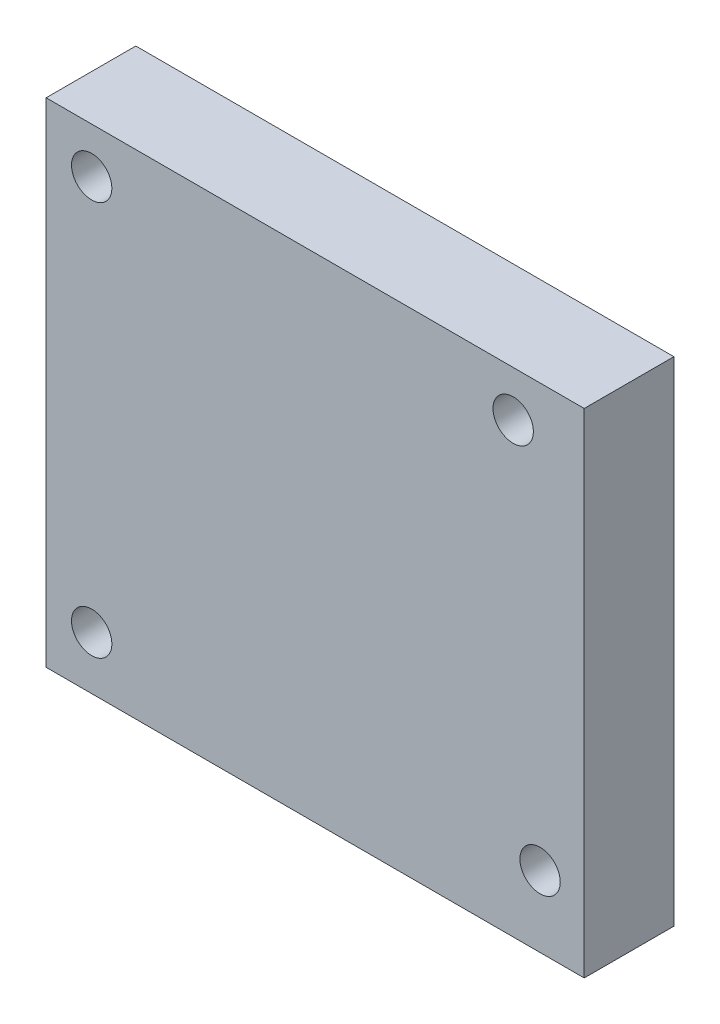
from build123d import *

# Parameters (mm, degrees)
SKETCH1_W           = 59.999999888
SKETCH1_H           = 55
SKETCH1_R           = 2.25
BOSS_EXTRUDE1_DEPTH = 10


with BuildPart() as part:
    # Sketch1 → Boss-Extrude1 (new body)
    with BuildSketch(Plane.XY):
        with Locations((0, -2.5)):
            Rectangle(SKETCH1_W, SKETCH1_H)
        with Locations((-24.919999944, 19.92)):
            Circle(SKETCH1_R, mode=Mode.SUBTRACT)
        with Locations((-24.919999944, -24.08)):
            Circle(SKETCH1_R, mode=Mode.SUBTRACT)
        with Locations((25.080000056, -22.08)):
            Circle(SKETCH1_R, mode=Mode.SUBTRACT)
        with Locations((22.080000056, 19.92)):
            Circle(SKETCH1_R, mode=Mode.SUBTRACT)
    extrude(amount=BOSS_EXTRUDE1_DEPTH)


solid = part.part
